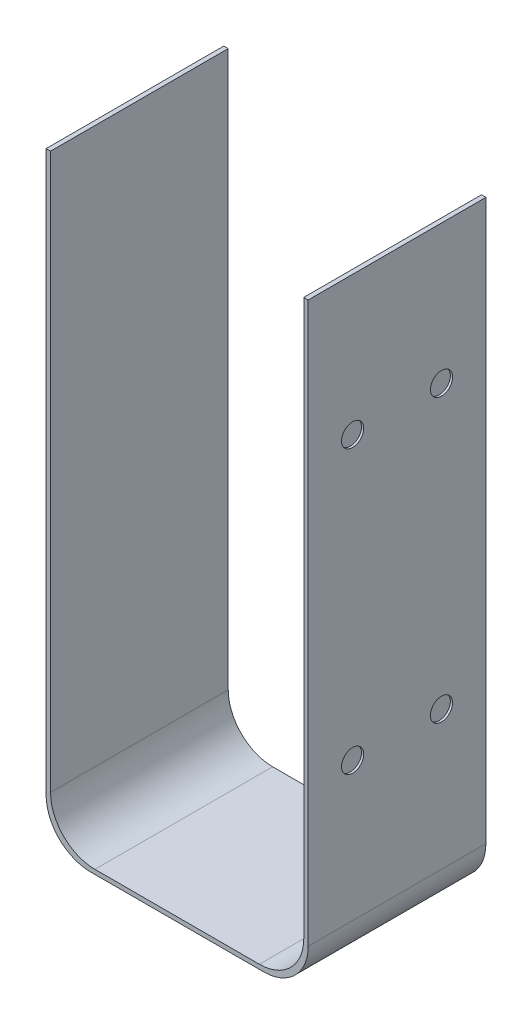
from build123d import *

# Parameters (mm, degrees)
DODANIE_WYCI_GNI_CIE1_DEPTH = 8
SZKIC2_R                    = 0.5
WYTNIJ_WYCI_GNI_CIE1_DEPTH  = 0.1
SZKIC3_R                    = 0.5
WYTNIJ_WYCI_GNI_CIE2_DEPTH  = 0.1


with BuildPart() as part:
    # Szkic1 → Dodanie-wyciągnięcie1 (new body)
    with BuildSketch(Plane.XY):
        with BuildLine():
            Line((-55.680131723, 42.864285714), (-55.680131723, 17.864285714))
            ThreePointArc((-55.680131723, 17.864285714), (-55.094345286, 16.450072152), (-53.680131723, 15.864285714))
            Line((-53.680131723, 15.864285714), (-46.280131723, 15.864285714))
            ThreePointArc((-46.280131723, 15.864285714), (-44.865918161, 16.450072152), (-44.280131723, 17.864285714))
            Line((-44.280131723, 17.864285714), (-44.280131723, 42.864285714))
            Line((-44.280131723, 42.864285714), (-44.080131723, 42.864285714))
            Line((-44.080131723, 42.864285714), (-44.080131723, 17.664285714))
            ThreePointArc((-44.080131723, 17.664285714), (-44.665918161, 16.250072152), (-46.080131723, 15.664285714))
            Line((-46.080131723, 15.664285714), (-53.880131723, 15.664285714))
            ThreePointArc((-53.880131723, 15.664285714), (-55.294345286, 16.250072152), (-55.880131723, 17.664285714))
            Line((-55.880131723, 17.664285714), (-55.880131723, 42.864285714))
            Line((-55.880131723, 42.864285714), (-55.680131723, 42.864285714))
        make_face()
    extrude(amount=DODANIE_WYCI_GNI_CIE1_DEPTH)

    # Szkic2 → Wytnij-wyciągnięcie1 (cut)
    with BuildSketch(Plane(origin=(-44.080131723, 0, 0), x_dir=(0, 0, -1), z_dir=(1, 0, 0))):
        with Locations((-2, 36.614285714)):
            Circle(SZKIC2_R)
        with Locations((-6, 36.614285714)):
            Circle(SZKIC2_R)
        with Locations((-6, 23.914285714)):
            Circle(SZKIC2_R)
        with Locations((-2, 23.914285714)):
            Circle(SZKIC2_R)
    extrude(amount=-WYTNIJ_WYCI_GNI_CIE1_DEPTH, mode=Mode.SUBTRACT)

    # Szkic3 → Wytnij-wyciągnięcie2 (cut)
    with BuildSketch(Plane.ZY.offset(55.880131723)):
        with Locations((2, 36.614285714)):
            Circle(SZKIC3_R)
        with Locations((6, 36.614285714)):
            Circle(SZKIC3_R)
        with Locations((6, 23.914285714)):
            Circle(SZKIC3_R)
        with Locations((2, 23.914285714)):
            Circle(SZKIC3_R)
    extrude(amount=-WYTNIJ_WYCI_GNI_CIE2_DEPTH, mode=Mode.SUBTRACT)


solid = part.part
